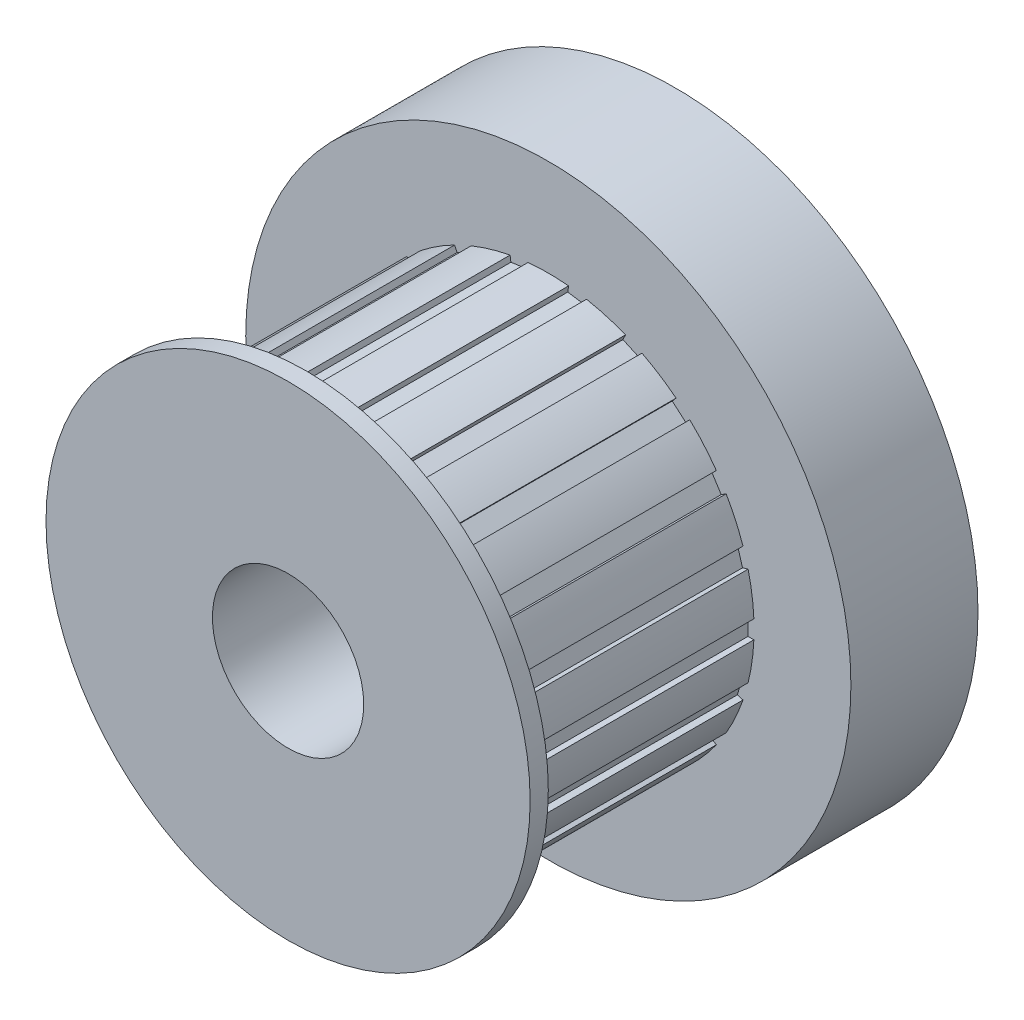
from build123d import *

# Parameters (mm, degrees)
SKETCH1_R           = 10.16
BOSS_EXTRUDE1_DEPTH = 0.762
SKETCH2_R           = 8.636
BOSS_EXTRUDE2_DEPTH = 10.16
SKETCH3_R           = 12.7
BOSS_EXTRUDE3_DEPTH = 5.334
SKETCH4_R           = 3.175
CUT_EXTRUDE1_DEPTH  = 25.654
SKETCH5_W           = 10.16
SKETCH5_H           = 0.762
CUT_EXTRUDE2_DEPTH  = 0.254
CIRPATTERN1_COUNT   = 22


with BuildPart() as part:
    # Sketch1 → Boss-Extrude1 (new body)
    with BuildSketch(Plane.XY):
        Circle(SKETCH1_R)
    extrude(amount=-BOSS_EXTRUDE1_DEPTH)

    # Sketch2 → Boss-Extrude2 (add)
    with BuildSketch(Plane(origin=(0, 0, -0.762), x_dir=(-1, 0, 0), z_dir=(0, 0, -1))):
        Circle(SKETCH2_R)
    extrude(amount=BOSS_EXTRUDE2_DEPTH)

    # Sketch3 → Boss-Extrude3 (add)
    with BuildSketch(Plane(origin=(0, 0, -10.922), x_dir=(-1, 0, 0), z_dir=(0, 0, -1))):
        Circle(SKETCH3_R)
    extrude(amount=BOSS_EXTRUDE3_DEPTH)

    # Sketch4 → Cut-Extrude1 (cut)
    with BuildSketch(Plane.XY):
        Circle(SKETCH4_R)
    extrude(amount=-CUT_EXTRUDE1_DEPTH, mode=Mode.SUBTRACT)

    # Sketch5 → Cut-Extrude2 (cut)
    with BuildSketch(Plane.ZY.offset(8.636)):
        with Locations((-5.842, 0)):
            Rectangle(SKETCH5_W, SKETCH5_H)
    cut_extrude2 = extrude(amount=-CUT_EXTRUDE2_DEPTH, mode=Mode.SUBTRACT)

    # CirPattern1: Cut-Extrude2 ×22 about axis
    cirpattern1_axis = Axis((0, 0, -16.256), (0, 0, 1))
    for i in range(1, CIRPATTERN1_COUNT):
        add(cut_extrude2.rotate(cirpattern1_axis, i * 360 / CIRPATTERN1_COUNT), mode=Mode.SUBTRACT)


solid = part.part
